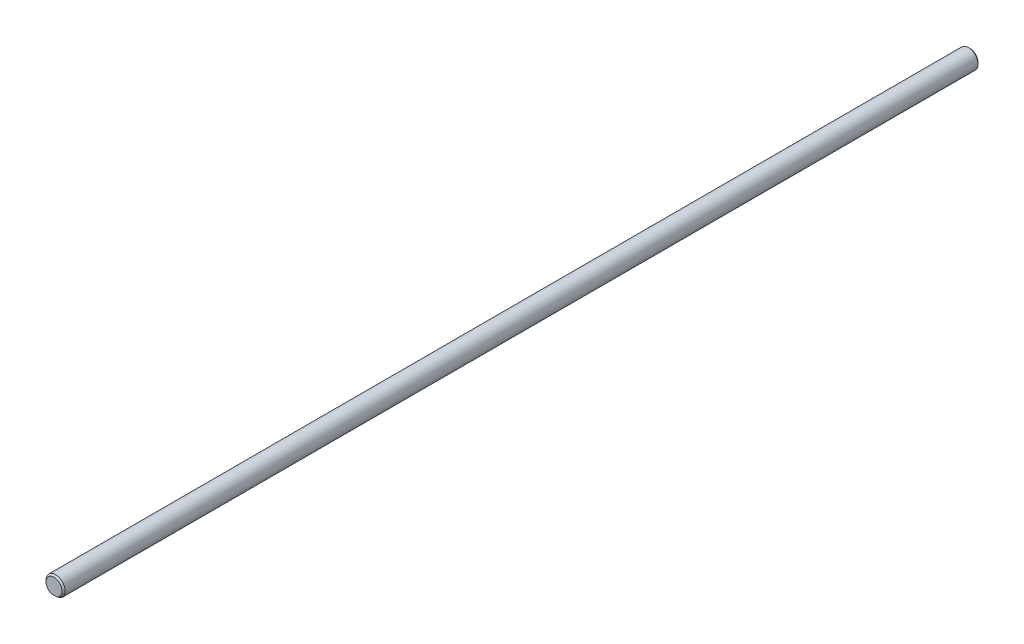
from build123d import *

# Parameters (mm, degrees)
CHAMFER1_SIZE = 0.5


with BuildPart() as part:
    # Sweep1: sweep along a path in Sketch2
    with BuildLine(Plane(origin=(0, 0, 0), x_dir=(1, 0, 0), z_dir=(0, 1, 0))) as sweep1_path:
        Line((0, -152.4), (0, 152.4))
    # Sketch1 → Sweep1 (sweep)
    with BuildSketch(Plane.XY):
        with BuildLine():
            Line((-1.905, -2.54), (1.905, -2.54))
            ThreePointArc((1.905, -2.54), (0, 3.175), (-1.905, -2.54))
        make_face()
    sweep(path=sweep1_path.line)

    # Chamfer1
    chamfer1_edges = [part.edges().sort_by_distance(p)[0] for p in [
        (0, 3.175, -152.4),
        (0, 3.175, 152.4),
    ]]
    chamfer(chamfer1_edges, length=CHAMFER1_SIZE)


solid = part.part
